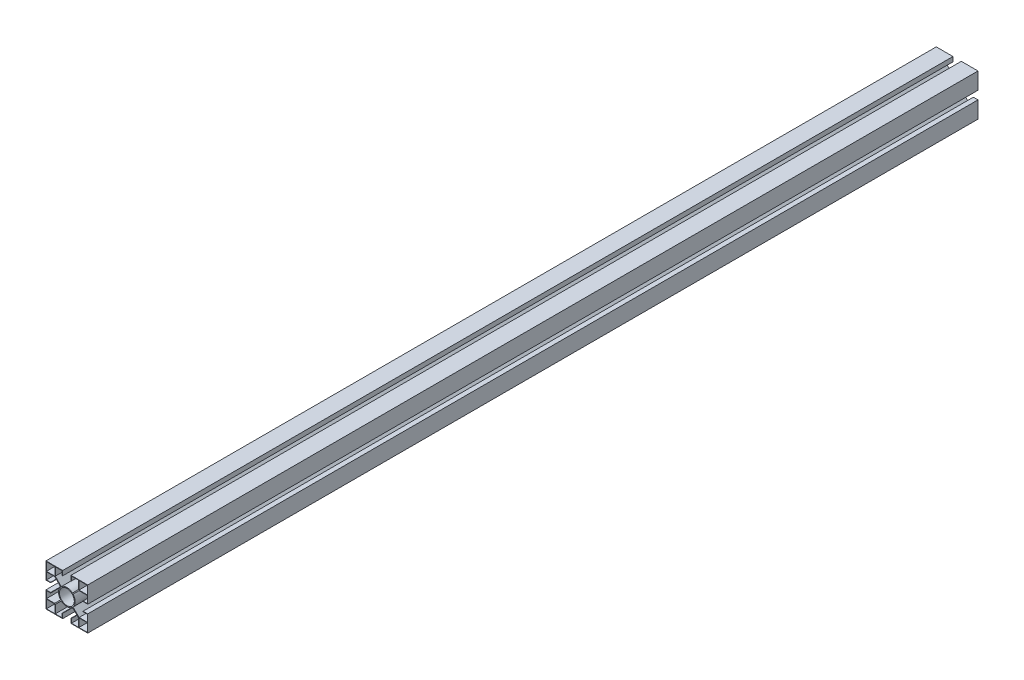
from build123d import *

# Parameters (mm, degrees)
ESBO_O1_W                = 9
ESBO_O1_H                = 9
ESBO_O1_R                = 8
RESSALTO_EXTRUS_O4_DEPTH = 960


with BuildPart() as part:
    # Esboço1 → Ressalto-extrusão4 (new body)
    with BuildSketch(Plane.XY):
        with BuildLine():
            Line((-4.5, 22.5), (-22.5, 22.5))
            Line((-22.5, 22.5), (-22.5, 4.5))
            Line((-22.5, 4.5), (-17.5, 4.5))
            Line((-17.5, 4.5), (-17.5, 5))
            Line((-17.5, 5), (-22, 5))
            Line((-22, 5), (-22, 12.5))
            Line((-22, 12.5), (-13.207106781, 12.5))
            Line((-13.207106781, 12.5), (-6.707685904, 6.000579123))
            ThreePointArc((-6.707685904, 6.000579123), (-9, 0), (-6.707685904, -6.000579123))
            Line((-6.707685904, -6.000579123), (-13.207106781, -12.5))
            Line((-13.207106781, -12.5), (-22, -12.5))
            Line((-22, -12.5), (-22, -5))
            Line((-22, -5), (-17.5, -5))
            Line((-17.5, -5), (-17.5, -4.5))
            Line((-17.5, -4.5), (-22.5, -4.5))
            Line((-22.5, -4.5), (-22.5, -22.5))
            Line((-22.5, -22.5), (-4.5, -22.5))
            Line((-4.5, -22.5), (-4.5, -17.5))
            Line((-4.5, -17.5), (-5, -17.5))
            Line((-5, -17.5), (-5, -22))
            Line((-5, -22), (-12.5, -22))
            Line((-12.5, -22), (-12.5, -13.207106781))
            Line((-12.5, -13.207106781), (-6.000579123, -6.707685904))
            ThreePointArc((-6.000579123, -6.707685904), (0, -9), (6.000579123, -6.707685904))
            Line((6.000579123, -6.707685904), (12.5, -13.207106781))
            Line((12.5, -13.207106781), (12.5, -22))
            Line((12.5, -22), (5, -22))
            Line((5, -22), (5, -17.5))
            Line((5, -17.5), (4.5, -17.5))
            Line((4.5, -17.5), (4.5, -22.5))
            Line((4.5, -22.5), (22.5, -22.5))
            Line((22.5, -22.5), (22.5, -4.5))
            Line((22.5, -4.5), (17.5, -4.5))
            Line((17.5, -4.5), (17.5, -5))
            Line((17.5, -5), (22, -5))
            Line((22, -5), (22, -12.5))
            Line((22, -12.5), (13.207106781, -12.5))
            Line((13.207106781, -12.5), (6.707685904, -6.000579123))
            ThreePointArc((6.707685904, -6.000579123), (9, 0), (6.707685904, 6.000579123))
            Line((6.707685904, 6.000579123), (13.207106781, 12.5))
            Line((13.207106781, 12.5), (22, 12.5))
            Line((22, 12.5), (22, 5))
            Line((22, 5), (17.5, 5))
            Line((17.5, 5), (17.5, 4.5))
            Line((17.5, 4.5), (22.5, 4.5))
            Line((22.5, 4.5), (22.5, 22.5))
            Line((22.5, 22.5), (4.5, 22.5))
            Line((4.5, 22.5), (4.5, 17.5))
            Line((4.5, 17.5), (5, 17.5))
            Line((5, 17.5), (5, 22))
            Line((5, 22), (12.5, 22))
            Line((12.5, 22), (12.5, 13.207106781))
            Line((12.5, 13.207106781), (6.000579123, 6.707685904))
            ThreePointArc((6.000579123, 6.707685904), (0, 9), (-6.000579123, 6.707685904))
            Line((-6.000579123, 6.707685904), (-12.5, 13.207106781))
            Line((-12.5, 13.207106781), (-12.5, 22))
            Line((-12.5, 22), (-5, 22))
            Line((-5, 22), (-5, 17.5))
            Line((-5, 17.5), (-4.5, 17.5))
            Line((-4.5, 17.5), (-4.5, 22.5))
        make_face()
        with Locations((17.5, 17.5)):
            Rectangle(ESBO_O1_W, ESBO_O1_H, mode=Mode.SUBTRACT)
        with Locations((-17.5, -17.5)):
            Rectangle(ESBO_O1_W, ESBO_O1_H, mode=Mode.SUBTRACT)
        with Locations((17.5, -17.5)):
            Rectangle(ESBO_O1_W, ESBO_O1_H, mode=Mode.SUBTRACT)
        with Locations((-17.5, 17.5)):
            Rectangle(ESBO_O1_W, ESBO_O1_H, mode=Mode.SUBTRACT)
        Circle(ESBO_O1_R, mode=Mode.SUBTRACT)
    extrude(amount=RESSALTO_EXTRUS_O4_DEPTH)


solid = part.part
